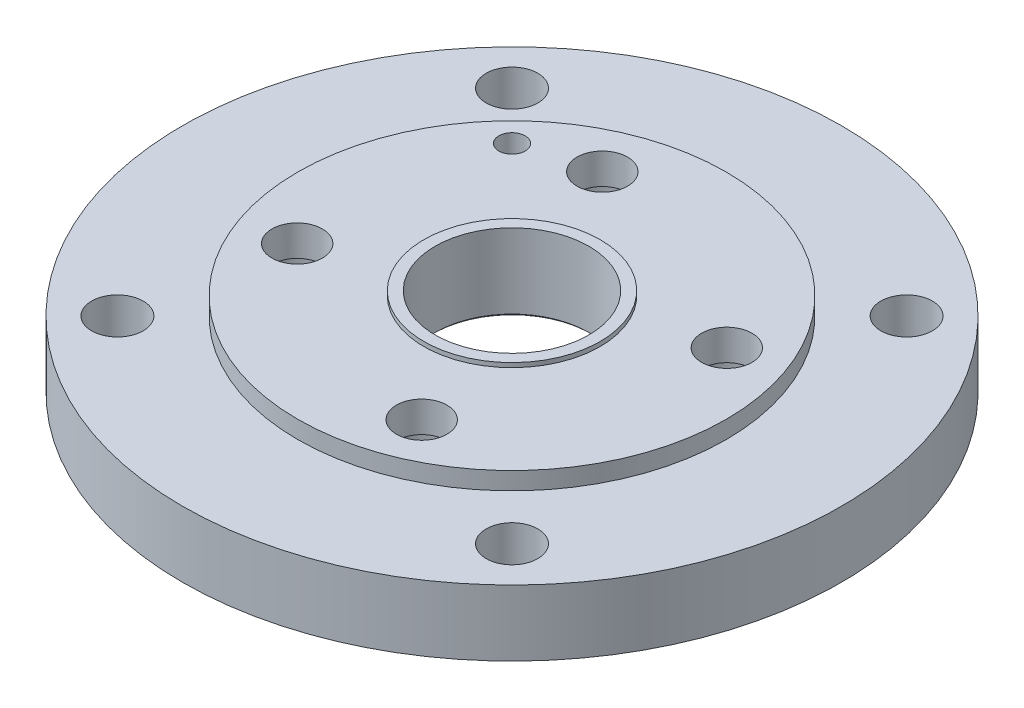
from build123d import *

# Parameters (mm, degrees)
CHAMFER_1_SIZE      = 1
CUT_EXTRUDE_1_REACH = 42
SKETCH_2_R          = 6
SKETCH_2_R_2        = 11.75
CUT_EXTRUDE_2_REACH = 42
SKETCH_3_R          = 11.5
SKETCH_4_R          = 17.5
CUT_EXTRUDE_3_DEPTH = 24


with BuildPart() as part:
    # 스케치1 → 회전1 (revolve)
    with BuildSketch(Plane.XY, mode=Mode.PRIVATE) as revolve_1_sk:
        Polygon((-150, 0), (-150, 30), (-97.5, 30), (-97.5, 38), (-40.15, 38), (-40.15, 40), (-35, 40), (-35, 5), (-43.5, 5), (-43.5, 0), align=None)
    revolve(revolve_1_sk.sketch.rotate(Axis((0, 0, 0), (0, 1, 0)), 270), axis=Axis((0, 0, 0), (0, 1, 0)))  # turned: the seam where the file's is

    # 모따기1
    chamfer_1_edges = [part.edges().sort_by_distance(p)[0] for p in [
        (0, 0, 43.5),
        (0, 5, 35),
    ]]
    chamfer(chamfer_1_edges, length=CHAMFER_1_SIZE)

    # 스케치2 → 컷-돌출1 (cut, up to next)
    with BuildSketch(Plane(origin=(0, 0, 0), x_dir=(1, 0, 0), z_dir=(0, 1, 0)), mode=Mode.PRIVATE) as cut_extrude_1_sk1:
        with Locations(Location((-60, 60, 0), (0, 0, 90))):  # turned: the seam where the file's is
            Circle(SKETCH_2_R)
    cut_extrude_1_tool1 = extrude(cut_extrude_1_sk1.sketch, amount=CUT_EXTRUDE_1_REACH, mode=Mode.PRIVATE) & part.part
    add(cut_extrude_1_tool1.solids().sort_by_distance((-60, 0, -60))[0], mode=Mode.SUBTRACT)
    # 스케치2 → 컷-돌출1 (cut, up to next)
    with BuildSketch(Plane(origin=(0, 0, 0), x_dir=(1, 0, 0), z_dir=(0, 1, 0)), mode=Mode.PRIVATE) as cut_extrude_1_sk2:
        with Locations(Location((-89.802561211, 89.802561211, 0), (0, 0, 90))):  # turned: the seam where the file's is
            Circle(SKETCH_2_R_2)
    cut_extrude_1_tool2 = extrude(cut_extrude_1_sk2.sketch, amount=CUT_EXTRUDE_1_REACH, mode=Mode.PRIVATE) & part.part
    add(cut_extrude_1_tool2.solids().sort_by_distance((-89.802561, 0, -89.802561))[0], mode=Mode.SUBTRACT)
    # 스케치2 → 컷-돌출1 (cut, up to next)
    with BuildSketch(Plane(origin=(0, 0, 0), x_dir=(1, 0, 0), z_dir=(0, 1, 0)), mode=Mode.PRIVATE) as cut_extrude_1_sk3:
        with Locations(Location((89.802561211, 89.802561211, 0), (0, 0, 90))):  # turned: the seam where the file's is
            Circle(SKETCH_2_R_2)
    cut_extrude_1_tool3 = extrude(cut_extrude_1_sk3.sketch, amount=CUT_EXTRUDE_1_REACH, mode=Mode.PRIVATE) & part.part
    add(cut_extrude_1_tool3.solids().sort_by_distance((89.802561, 0, -89.802561))[0], mode=Mode.SUBTRACT)
    # 스케치2 → 컷-돌출1 (cut, up to next)
    with BuildSketch(Plane(origin=(0, 0, 0), x_dir=(1, 0, 0), z_dir=(0, 1, 0)), mode=Mode.PRIVATE) as cut_extrude_1_sk4:
        with Locations(Location((89.802561211, -89.802561211, 0), (0, 0, 90))):  # turned: the seam where the file's is
            Circle(SKETCH_2_R_2)
    cut_extrude_1_tool4 = extrude(cut_extrude_1_sk4.sketch, amount=CUT_EXTRUDE_1_REACH, mode=Mode.PRIVATE) & part.part
    add(cut_extrude_1_tool4.solids().sort_by_distance((89.802561, 0, 89.802561))[0], mode=Mode.SUBTRACT)
    # 스케치2 → 컷-돌출1 (cut, up to next)
    with BuildSketch(Plane(origin=(0, 0, 0), x_dir=(1, 0, 0), z_dir=(0, 1, 0)), mode=Mode.PRIVATE) as cut_extrude_1_sk5:
        with Locations(Location((-89.802561211, -89.802561211, 0), (0, 0, 90))):  # turned: the seam where the file's is
            Circle(SKETCH_2_R_2)
    cut_extrude_1_tool5 = extrude(cut_extrude_1_sk5.sketch, amount=CUT_EXTRUDE_1_REACH, mode=Mode.PRIVATE) & part.part
    add(cut_extrude_1_tool5.solids().sort_by_distance((-89.802561, 0, 89.802561))[0], mode=Mode.SUBTRACT)

    # 스케치3 → 컷-돌출2 (cut, up to next)
    with BuildSketch(Plane(origin=(0, 0, 0), x_dir=(1, 0, 0), z_dir=(0, 1, 0)), mode=Mode.PRIVATE) as cut_extrude_2_sk1:
        with Locations(Location((-28.338059011, 69.440293861, 0), (0, 0, 90))):  # turned: the seam where the file's is
            Circle(SKETCH_3_R)
    cut_extrude_2_tool1 = extrude(cut_extrude_2_sk1.sketch, amount=CUT_EXTRUDE_2_REACH, mode=Mode.PRIVATE) & part.part
    add(cut_extrude_2_tool1.solids().sort_by_distance((-28.338059, 0, -69.440294))[0], mode=Mode.SUBTRACT)
    # 스케치3 → 컷-돌출2 (cut, up to next)
    with BuildSketch(Plane(origin=(0, 0, 0), x_dir=(1, 0, 0), z_dir=(0, 1, 0)), mode=Mode.PRIVATE) as cut_extrude_2_sk2:
        with Locations(Location((69.440293861, 28.338059011, 0), (0, 0, 90))):  # turned: the seam where the file's is
            Circle(SKETCH_3_R)
    cut_extrude_2_tool2 = extrude(cut_extrude_2_sk2.sketch, amount=CUT_EXTRUDE_2_REACH, mode=Mode.PRIVATE) & part.part
    add(cut_extrude_2_tool2.solids().sort_by_distance((69.440294, 0, -28.338059))[0], mode=Mode.SUBTRACT)
    # 스케치3 → 컷-돌출2 (cut, up to next)
    with BuildSketch(Plane(origin=(0, 0, 0), x_dir=(1, 0, 0), z_dir=(0, 1, 0)), mode=Mode.PRIVATE) as cut_extrude_2_sk3:
        with Locations(Location((28.338059011, -69.440293861, 0), (0, 0, 90))):  # turned: the seam where the file's is
            Circle(SKETCH_3_R)
    cut_extrude_2_tool3 = extrude(cut_extrude_2_sk3.sketch, amount=CUT_EXTRUDE_2_REACH, mode=Mode.PRIVATE) & part.part
    add(cut_extrude_2_tool3.solids().sort_by_distance((28.338059, 0, 69.440294))[0], mode=Mode.SUBTRACT)
    # 스케치3 → 컷-돌출2 (cut, up to next)
    with BuildSketch(Plane(origin=(0, 0, 0), x_dir=(1, 0, 0), z_dir=(0, 1, 0)), mode=Mode.PRIVATE) as cut_extrude_2_sk4:
        with Locations(Location((-69.440293861, -28.338059011, 0), (0, 0, 90))):  # turned: the seam where the file's is
            Circle(SKETCH_3_R)
    cut_extrude_2_tool4 = extrude(cut_extrude_2_sk4.sketch, amount=CUT_EXTRUDE_2_REACH, mode=Mode.PRIVATE) & part.part
    add(cut_extrude_2_tool4.solids().sort_by_distance((-69.440294, 0, 28.338059))[0], mode=Mode.SUBTRACT)

    # 스케치4 → 컷-돌출3 (cut)
    with BuildSketch(Plane(origin=(0, 0, 0), x_dir=(1, 0, 0), z_dir=(0, 1, 0))):
        with Locations(Location((-28.338059011, 69.440293861, 0), (0, 0, 270))):  # turned: the seam where the file's is
            Circle(SKETCH_4_R)
        with Locations(Location((-69.440293861, -28.338059011, 0), (0, 0, 270))):  # turned: the seam where the file's is
            Circle(SKETCH_4_R)
        with Locations(Location((69.440293861, 28.338059011, 0), (0, 0, 270))):  # turned: the seam where the file's is
            Circle(SKETCH_4_R)
        with Locations(Location((28.338059011, -69.440293861, 0), (0, 0, 270))):  # turned: the seam where the file's is
            Circle(SKETCH_4_R)
    extrude(amount=CUT_EXTRUDE_3_DEPTH, mode=Mode.SUBTRACT)


solid = part.part
